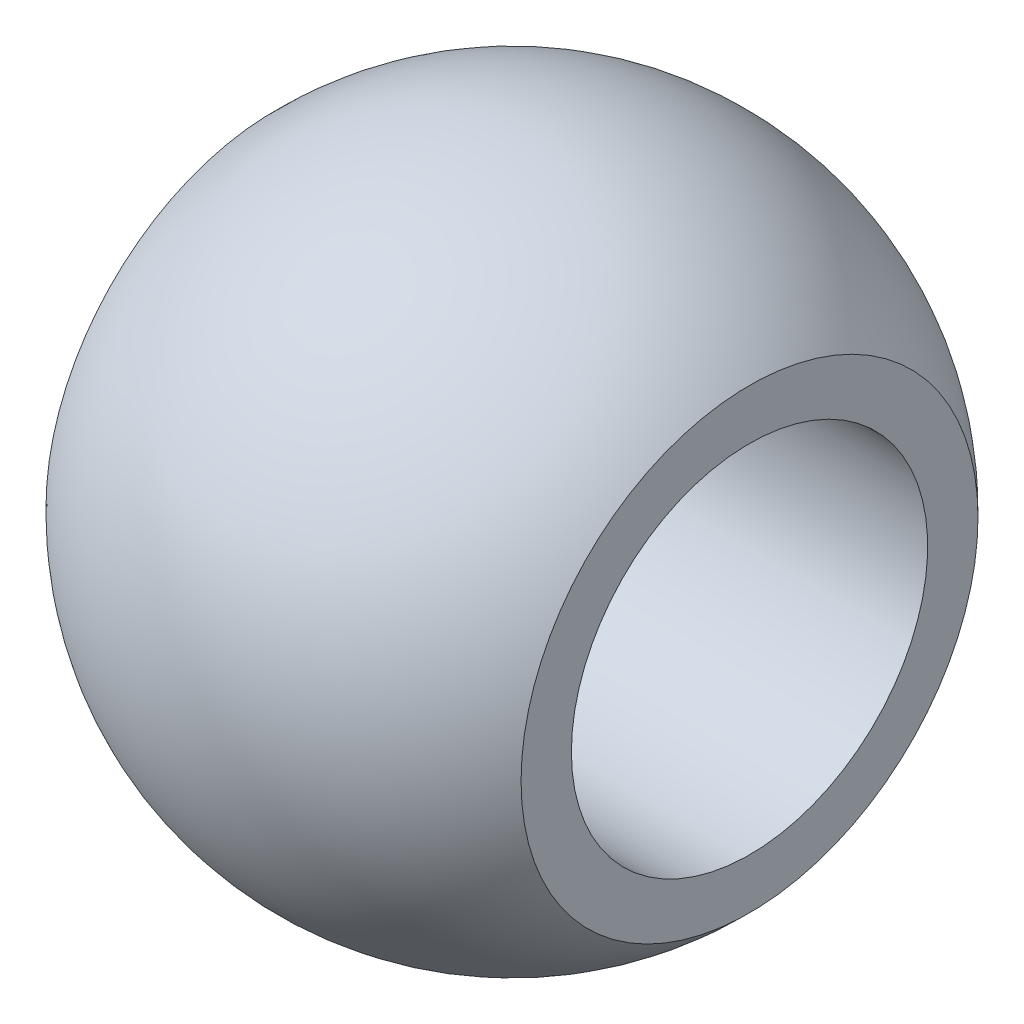
from build123d import *


with BuildPart() as part:
    # Sketch1 → Revolve1 (revolve)
    with BuildSketch(Plane.XY):
        with BuildLine():
            Line((8, 7.694803441), (8, 6))
            Line((8, 6), (-8, 6))
            Line((-8, 6), (-8, 7.694803441))
            ThreePointArc((-8, 7.694803441), (0, 11.1), (8, 7.694803441))
        make_face()
    revolve(axis=Axis((0, 0, 0), (1, 0, 0)))


solid = part.part
